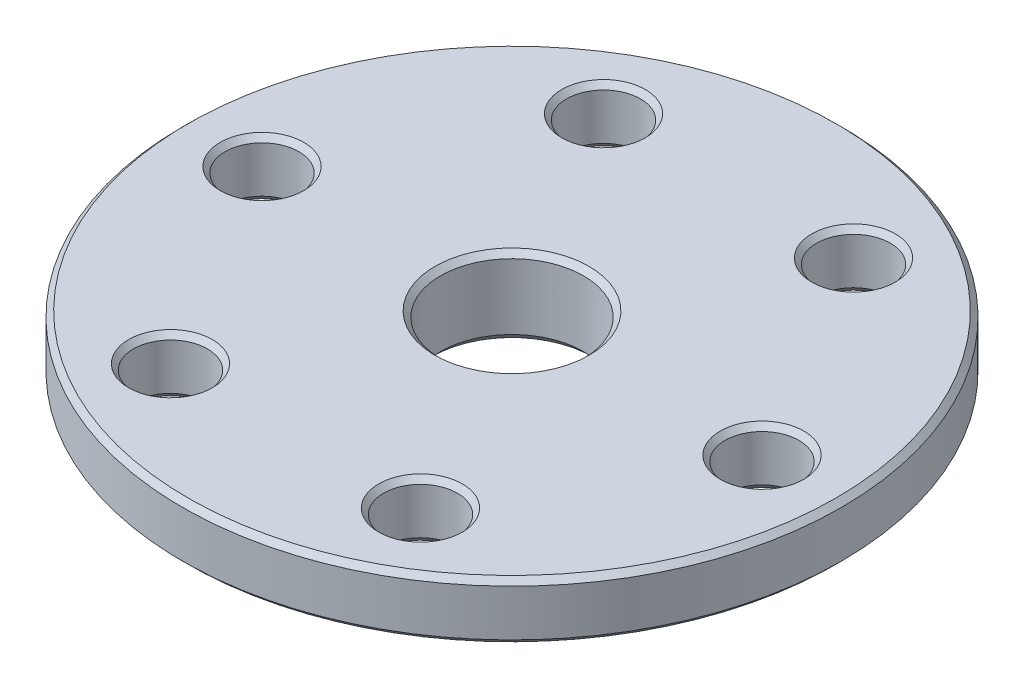
from build123d import *

# Parameters (mm, degrees)
CIRPATTERN1_COUNT = 6
CHAMFER2_SIZE     = 1.27
CHAMFER3_SIZE     = 0.762


with BuildPart() as part:
    # Sketch1 → Revolve1 (revolve)
    with BuildSketch(Plane.XY, mode=Mode.PRIVATE) as revolve1_sk:
        Polygon((-46.0375, -2.425), (-25.3873, -2.425), (-25.3873, -5.6), (-10, -5.6), (-10, 5.6), (-46.0375, 5.6), align=None)
    revolve(revolve1_sk.sketch.rotate(Axis((0, -8.7159552, 0), (0, 1, 0)), 180), axis=Axis((0, -8.7159552, 0), (0, 1, 0)))  # turned: the seam where the file's is

    # Sketch2 → 3_8 Clearance Hole1 (revolve, cut)
    with BuildSketch(Plane(origin=(34.925, 5.6, 0), x_dir=(0, 0, 1), z_dir=(1, 0, 0))):
        Polygon((0, 0), (0, 8.025), (5.842, 8.025), (5.15874, 7.238999282), (5.15874, 0.786000718), (5.842, 0), align=None)
    f_3_8_clearance_hole1 = revolve(axis=Axis((34.925, 11.95, 0), (0, -1, 0)), mode=Mode.SUBTRACT)

    # CirPattern1: 3_8 Clearance Hole1 ×6 about axis
    cirpattern1_axis = Axis((0, 0, 0), (0, 1, 0))
    for i in range(1, CIRPATTERN1_COUNT):
        add(f_3_8_clearance_hole1.rotate(cirpattern1_axis, i * 360 / CIRPATTERN1_COUNT), mode=Mode.SUBTRACT)

    # Chamfer2
    chamfer2_edges = [part.edges().sort_by_distance(p)[0] for p in [
        (-10, -5.6, 0),
    ]]
    chamfer(chamfer2_edges, length=CHAMFER2_SIZE)

    # Chamfer3
    chamfer3_edges = [part.edges().sort_by_distance(p)[0] for p in [
        (-25.3873, -5.6, 0),
        (-46.0375, -2.425, 0),
        (-46.0375, 5.6, 0),
        (-10, 5.6, 0),
    ]]
    chamfer(chamfer3_edges, length=CHAMFER3_SIZE)


solid = part.part
